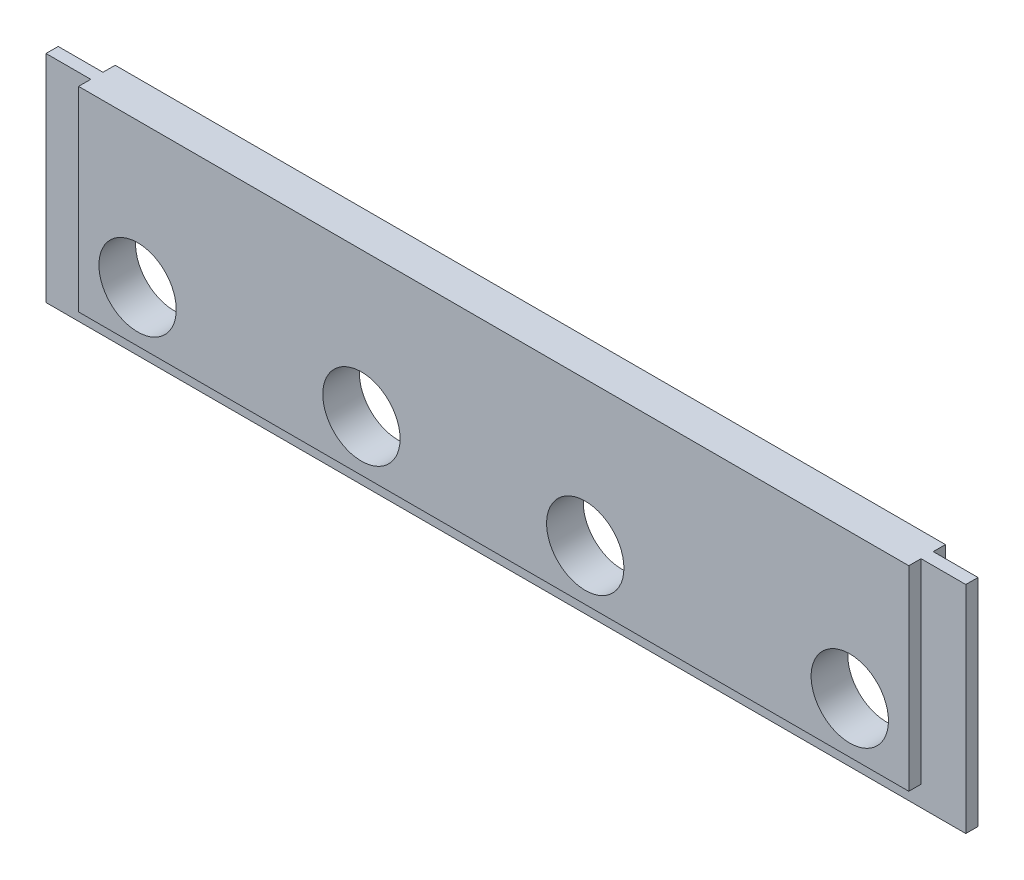
from build123d import *

# Parameters (mm, degrees)
SKETCH1_W           = 226
SKETCH1_H           = 53
BOSS_EXTRUDE1_DEPTH = 9
SKETCH3_R           = 9.5
CUT_EXTRUDE1_DEPTH  = 9
SKETCH2_W           = 11
SKETCH2_H           = 3
CUT_EXTRUDE2_DEPTH  = 54
SKETCH4_W           = 3
SKETCH4_H           = 5
CUT_EXTRUDE3_DEPTH  = 227


with BuildPart() as part:
    # Sketch1 → Boss-Extrude1 (new body)
    with BuildSketch(Plane.XY):
        with Locations((0, 0.4802203)):
            Rectangle(SKETCH1_W, SKETCH1_H)
    extrude(amount=BOSS_EXTRUDE1_DEPTH)

    # Sketch3 → Cut-Extrude1 (cut)
    with BuildSketch(Plane.XY.offset(9)):
        with Locations((-87.5, -8.5197797)):
            Circle(SKETCH3_R)
        with Locations((-32.5, -8.5197797)):
            Circle(SKETCH3_R)
        with Locations((22.5, -8.5197797)):
            Circle(SKETCH3_R)
        with Locations((87.5, -8.5197797)):
            Circle(SKETCH3_R)
    extrude(amount=-CUT_EXTRUDE1_DEPTH, mode=Mode.SUBTRACT)

    # Sketch2 → Cut-Extrude2 (cut, through all)
    with BuildSketch(Plane.XZ.offset(26.0197797)):
        with Locations((-107.5, 7.5)):
            Rectangle(SKETCH2_W, SKETCH2_H)
        with Locations((-107.5, 1.5)):
            Rectangle(SKETCH2_W, SKETCH2_H)
        with Locations((107.5, 7.5)):
            Rectangle(SKETCH2_W, SKETCH2_H)
        with Locations((107.5, 1.5)):
            Rectangle(SKETCH2_W, SKETCH2_H)
    extrude(amount=-CUT_EXTRUDE2_DEPTH, mode=Mode.SUBTRACT)

    # Sketch4 → Cut-Extrude3 (cut, through all)
    with BuildSketch(Plane.ZY.offset(113)):
        Polygon((0, -21.0197797), (0, -26.0197797), (3, -26.0197797), (3, -23.123504735), (3, -21.0197797), align=None)
        with Locations((7.5, -23.5197797)):
            Rectangle(SKETCH4_W, SKETCH4_H)
    extrude(amount=-CUT_EXTRUDE3_DEPTH, mode=Mode.SUBTRACT)


solid = part.part
